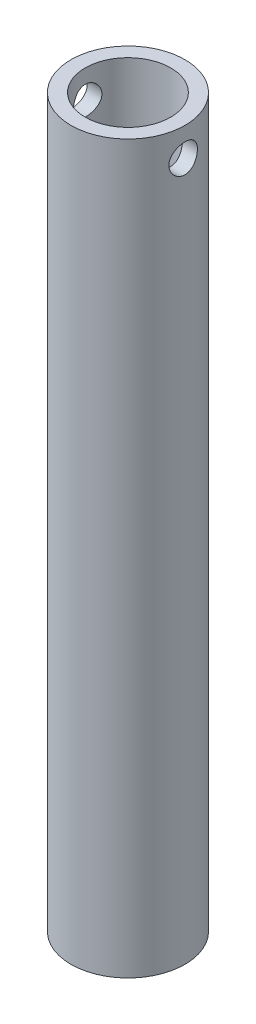
from build123d import *

# Parameters (mm, degrees)
SKETCH1_R               = 12.7
SKETCH1_R_2             = 9.525
BOSS_EXTRUDE1_DEPTH     = 161.925
SKETCH2_R               = 3.175
CUT_EXTRUDE1_DEPTH      = 13.7
CUT_EXTRUDE1_DEPTH_BACK = 13.7


with BuildPart() as part:
    # Sketch1 → Boss-Extrude1 (new body)
    with BuildSketch(Plane(origin=(0, 0, 0), x_dir=(1, 0, 0), z_dir=(0, 1, 0))):
        Circle(SKETCH1_R)
        Circle(SKETCH1_R_2, mode=Mode.SUBTRACT)
    extrude(amount=BOSS_EXTRUDE1_DEPTH)

    # Sketch2 → Cut-Extrude1 (cut, two sides)
    with BuildSketch(Plane(origin=(0, 0, 0), x_dir=(0, 0, -1), z_dir=(1, 0, 0))) as cut_extrude1_sk:
        with Locations((0, 155.575)):
            Circle(SKETCH2_R)
    extrude(amount=CUT_EXTRUDE1_DEPTH, mode=Mode.SUBTRACT)
    extrude(cut_extrude1_sk.sketch, amount=-CUT_EXTRUDE1_DEPTH_BACK, mode=Mode.SUBTRACT)


solid = part.part
